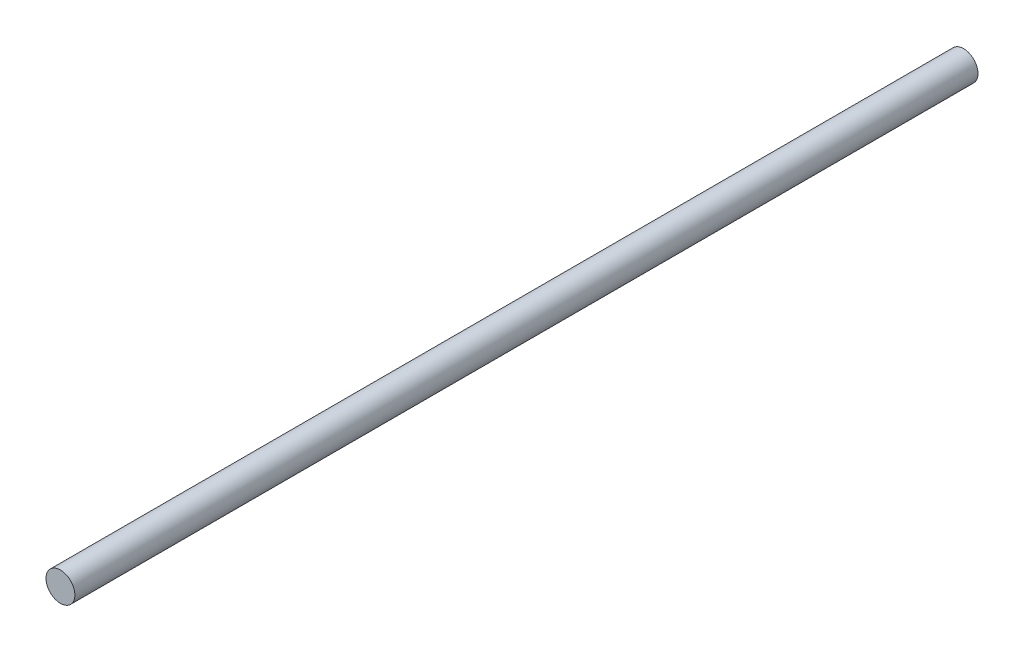
from build123d import *

# Parameters (mm, degrees)
IZIM1_R                     = 4
Y_KSEKLIK_EKSTR_ZYON1_DEPTH = 250


with BuildPart() as part:
    # Çizim1 → Yükseklik-Ekstrüzyon1 (new body)
    with BuildSketch(Plane.XY):
        Circle(IZIM1_R)
    extrude(amount=Y_KSEKLIK_EKSTR_ZYON1_DEPTH)


solid = part.part
